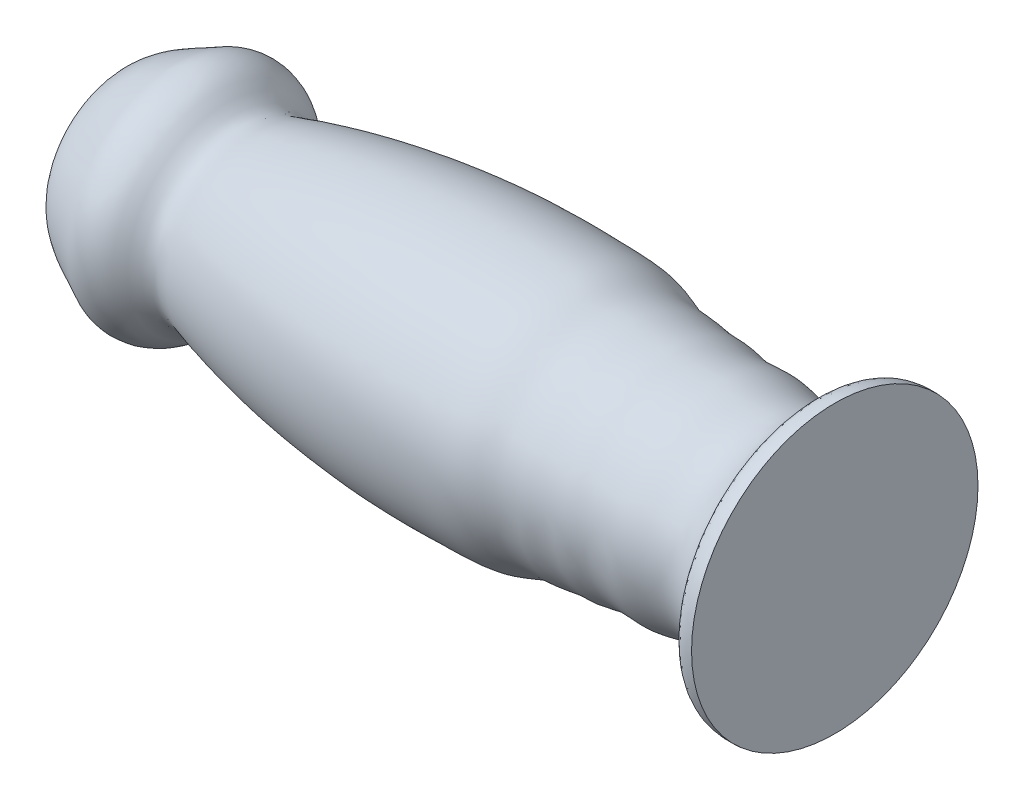
from build123d import *


with BuildPart() as part:
    # Sketch2 → Revolve2 (revolve)
    with BuildSketch(Plane(origin=(0, 0, 0), x_dir=(1, 0, 0), z_dir=(0, 1, 0))):
        with BuildLine():
            Line((76.2, 15.234532857), (76.2, 0))
            Line((76.2, 0), (0, 0))
            add(Edge.make_bspline(
                [(0, 0), (-0.014289391, 1.477508746), (0.166038156, 4.242535131), (-0.326008407, 7.613464171), (2.248859267, 9.905280421), (4.75236384, 10.881299996), (7.331427815, 12.366628487), (10.548485335, 11.800107252), (12.448666715, 8.78028007), (14.92963696, 9.716215681), (17.742028608, 10.473458193), (23.071490121, 11.718792526), (28.779272147, 12.563314793), (35.418965974, 13.182409845), (40.362042102, 13.299972389), (45.56838215, 13.178735478), (49.263443361, 13.094711309), (52.135800836, 11.638172959), (54.624924773, 11.709715004), (56.55814898, 11.246325334), (58.68125309, 11.360366094), (60.989342375, 10.634752517), (64.46421358, 11.339014335), (69.215818638, 9.25716668), (73.340551141, 12.181777706), (74.507206244, 15.30214845), (75.720104048, 15.243419629), (76.2, 15.234532857)],
                knots=[0, 0, 0, 0, 0.05525126, 0.078688521, 0.114575814, 0.157673263, 0.17398238, 0.21451189, 0.256403577, 0.27071977, 0.29874034, 0.358373655, 0.455777814, 0.496148444, 0.586000627, 0.624141103, 0.674585825, 0.710130609, 0.73065859, 0.758425186, 0.777505227, 0.802582219, 0.839310577, 0.89493798, 0.967427692, 0.981726829, 1, 1, 1, 1], degree=3))
        make_face()
    revolve(axis=Axis((76.2, 0, 0), (-1, 0, 0)))


solid = part.part
